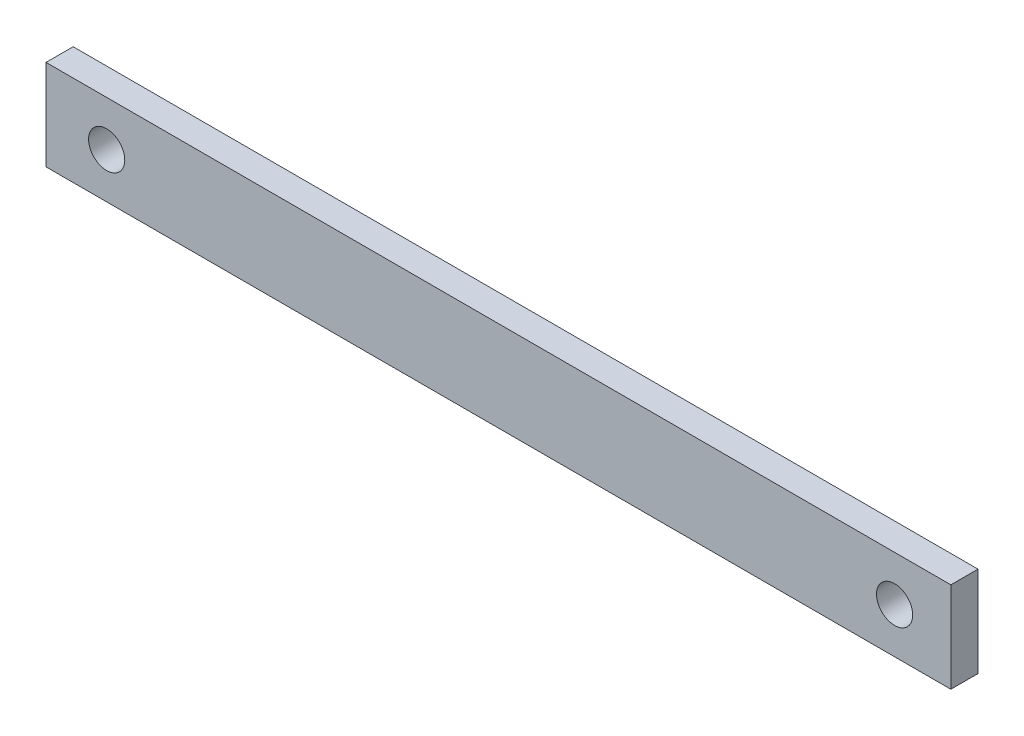
from build123d import *

# Parameters (mm, degrees)
SKETCH1_W           = 100
SKETCH1_H           = 10
BOSS_EXTRUDE1_DEPTH = 3
SKETCH2_R           = 2
CUT_EXTRUDE1_DEPTH  = 10


with BuildPart() as part:
    # Sketch1 → Boss-Extrude1 (new body)
    with BuildSketch(Plane.XY):
        Rectangle(SKETCH1_W, SKETCH1_H)
    extrude(amount=BOSS_EXTRUDE1_DEPTH)

    # Sketch2 → Cut-Extrude1 (cut)
    with BuildSketch(Plane.XY.offset(3)):
        with Locations((-43.295281707, 0)):
            Circle(SKETCH2_R)
        with Locations((43.782882982, 0)):
            Circle(SKETCH2_R)
    extrude(amount=-CUT_EXTRUDE1_DEPTH, mode=Mode.SUBTRACT)


solid = part.part
